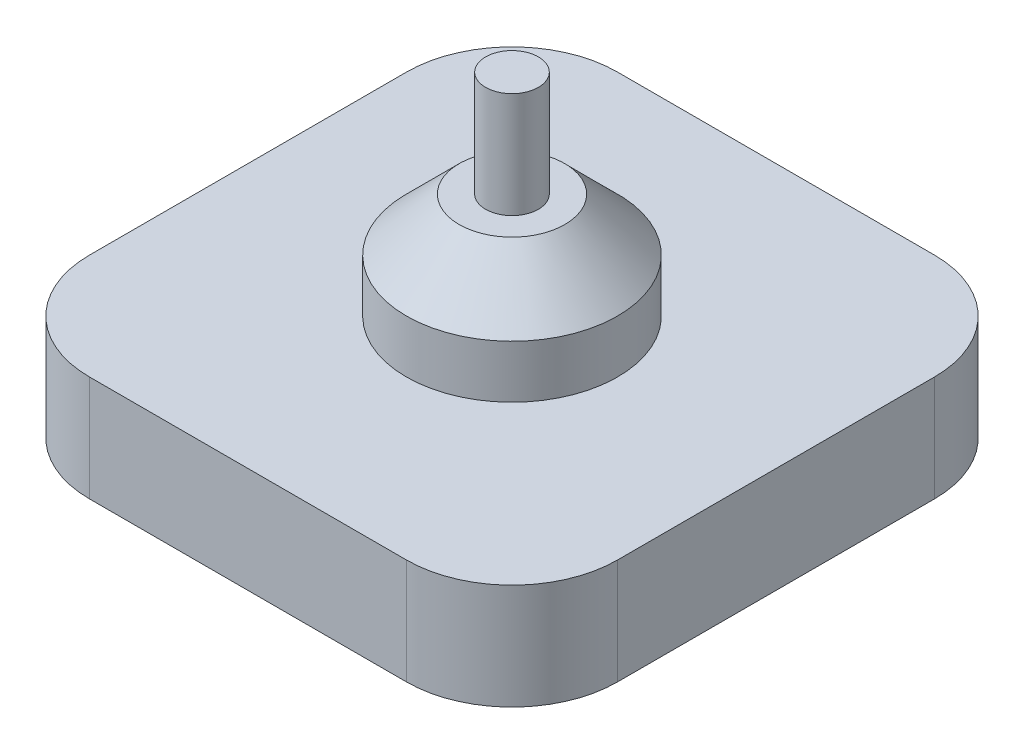
from build123d import *

# Parameters (mm, degrees)
SKETCH1_W           = 500
SKETCH1_H           = 500
BOSS_EXTRUDE1_DEPTH = 100
SKETCH2_R           = 100
BOSS_EXTRUDE2_DEPTH = 100
SKETCH3_R           = 25
BOSS_EXTRUDE3_DEPTH = 100
CHAMFER1_SIZE       = 50
FILLET1_R           = 100


with BuildPart() as part:
    # Sketch1 → Boss-Extrude1 (new body)
    with BuildSketch(Plane(origin=(0, 0, 0), x_dir=(1, 0, 0), z_dir=(0, 1, 0))):
        Rectangle(SKETCH1_W, SKETCH1_H)
    extrude(amount=BOSS_EXTRUDE1_DEPTH)

    # Sketch2 → Boss-Extrude2 (add)
    with BuildSketch(Plane(origin=(0, 100, 0), x_dir=(1, 0, 0), z_dir=(0, 1, 0))):
        Circle(SKETCH2_R)
    extrude(amount=BOSS_EXTRUDE2_DEPTH)

    # Sketch3 → Boss-Extrude3 (add)
    with BuildSketch(Plane(origin=(0, 200, 0), x_dir=(1, 0, 0), z_dir=(0, 1, 0))):
        Circle(SKETCH3_R)
    extrude(amount=BOSS_EXTRUDE3_DEPTH)

    # Chamfer1
    chamfer1_edges = [part.edges().sort_by_distance(p)[0] for p in [
        (-100, 200, 0),
    ]]
    chamfer(chamfer1_edges, length=CHAMFER1_SIZE)

    # Fillet1
    fillet1_edges = [part.edges().sort_by_distance(p)[0] for p in [
        (250, 50, -250),
        (250, 50, 250),
        (-250, 50, -250),
        (-250, 50, 250),
    ]]
    fillet(fillet1_edges, radius=FILLET1_R)


solid = part.part
